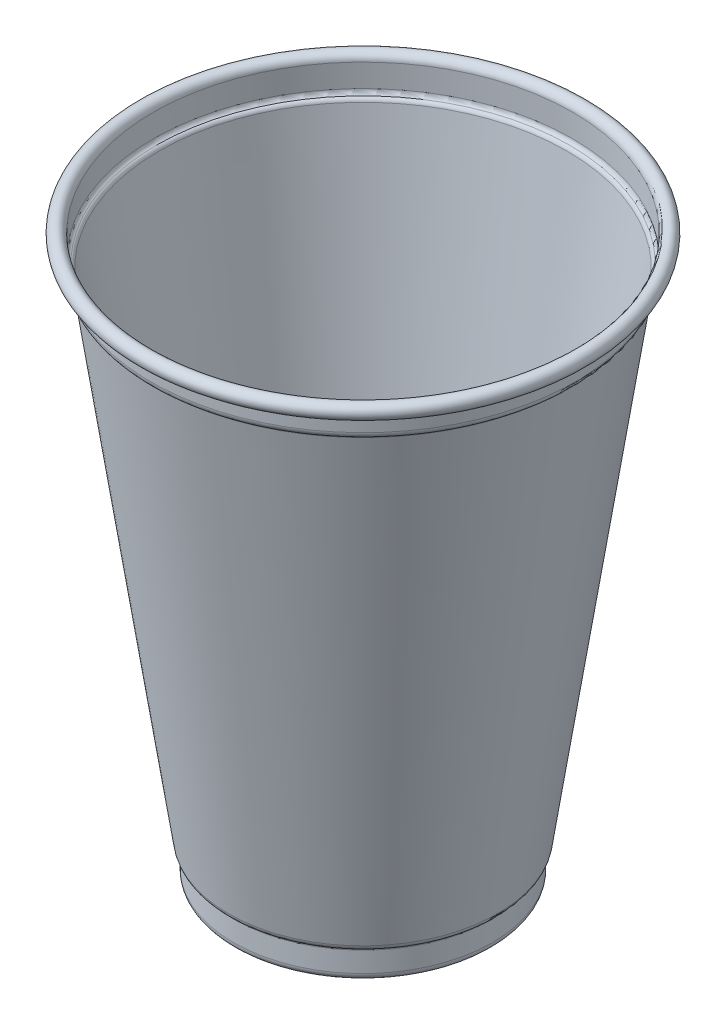
from build123d import *


with BuildPart() as part:
    # Sketch1 → Revolve2 (revolve)
    with BuildSketch(Plane.XY):
        with BuildLine():
            Line((0, 0.85), (0, 0.35))
            Line((0, 0.35), (-17.680926155, 0.35))
            ThreePointArc((-17.680926155, 0.35), (-17.816649115, 0.331226847), (-17.942180284, 0.276317112))
            Line((-17.942180284, 0.276317112), (-18.848272918, -0.278951337))
            ThreePointArc((-18.848272918, -0.278951337), (-19.224866424, -0.44368054), (-19.632035304, -0.5))
            Line((-19.632035304, -0.5), (-26.12590707, -0.5))
            ThreePointArc((-26.12590707, -0.5), (-27.199116334, -0.047960817), (-27.62548208, 1.035704167))
            Line((-27.62548208, 1.035704167), (-27.524234593, 5.288098611))
            ThreePointArc((-27.524234593, 5.288098611), (-27.59951284, 5.564067693), (-27.813757421, 5.753606629))
            ThreePointArc((-27.813757421, 5.753606629), (-28.384890548, 6.217286474), (-28.666873265, 6.896755234))
            Line((-28.666873265, 6.896755234), (-44.048657538, 111.772557094))
            ThreePointArc((-44.048657538, 111.772557094), (-44.146616467, 112.004287044), (-44.345023746, 112.15897794))
            ThreePointArc((-44.345023746, 112.15897794), (-45.003502218, 112.712059714), (-45.25, 113.535911758))
            Line((-45.25, 113.535911758), (-45.25, 118.435222207))
            ThreePointArc((-45.25, 118.435222207), (-47.188446327, 118.984816692), (-45.826915539, 117.499602171))
            Line((-45.826915539, 117.499602171), (-45.600481412, 117.053809985))
            ThreePointArc((-45.600481412, 117.053809985), (-47.614602101, 119.246335387), (-44.75, 118.435222207))
            Line((-44.75, 118.435222207), (-44.75, 113.535911758))
            ThreePointArc((-44.75, 113.535911758), (-44.585668145, 112.986677062), (-44.146682498, 112.617955879))
            ThreePointArc((-44.146682498, 112.617955879), (-43.749867938, 112.308574088), (-43.553950081, 111.845114187))
            Line((-43.553950081, 111.845114187), (-28.172165808, 6.969312327))
            ThreePointArc((-28.172165808, 6.969312327), (-27.98417733, 6.516333154), (-27.603421912, 6.207213257))
            ThreePointArc((-27.603421912, 6.207213257), (-27.174932749, 5.828135387), (-27.024376257, 5.276197222))
            Line((-27.024376257, 5.276197222), (-27.125623743, 1.023802778))
            ThreePointArc((-27.125623743, 1.023802778), (-26.841379913, 0.301359455), (-26.12590707, 0))
            Line((-26.12590707, 0), (-19.632035304, 0))
            ThreePointArc((-19.632035304, 0), (-19.360589384, 0.037546306), (-19.109527047, 0.147365775))
            Line((-19.109527047, 0.147365775), (-18.203434412, 0.702634225))
            ThreePointArc((-18.203434412, 0.702634225), (-17.952372075, 0.812453694), (-17.680926155, 0.85))
            Line((-17.680926155, 0.85), (0, 0.85))
        make_face()
    revolve(axis=Axis((0, 0, 0), (0, 1, 0)))


solid = part.part
